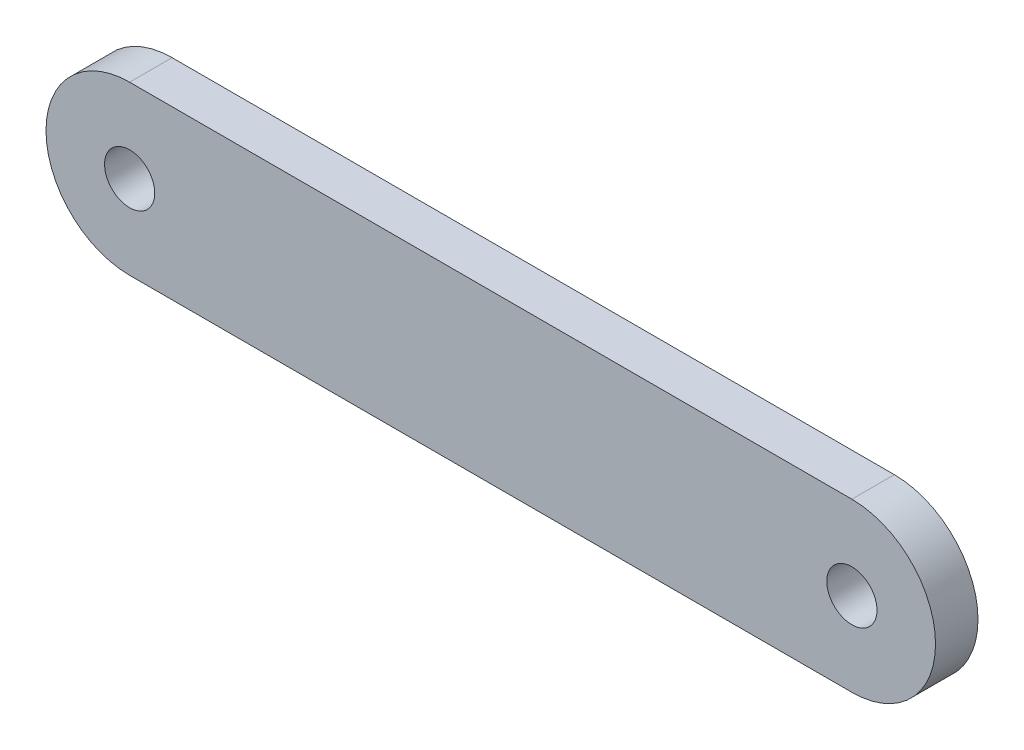
from build123d import *

# Parameters (mm, degrees)
SKETCH_2_R      = 0.75
EXTRUDE_1_DEPTH = 0.635


with BuildPart() as part:
    # 草圖2 → 填料-伸長1 (new body, symmetric)
    with BuildSketch(Plane.XY):
        with BuildLine():
            Line((-10.795, 2.5), (10.795, 2.5))
            ThreePointArc((10.795, 2.5), (13.295, 0), (10.795, -2.5))
            Line((10.795, -2.5), (-10.795, -2.5))
            ThreePointArc((-10.795, -2.5), (-13.295, 0), (-10.795, 2.5))
        make_face()
        with Locations((-10.795, 0)):
            Circle(SKETCH_2_R, mode=Mode.SUBTRACT)
        with Locations((10.795, 0)):
            Circle(SKETCH_2_R, mode=Mode.SUBTRACT)
    extrude(amount=EXTRUDE_1_DEPTH, both=True)


solid = part.part
